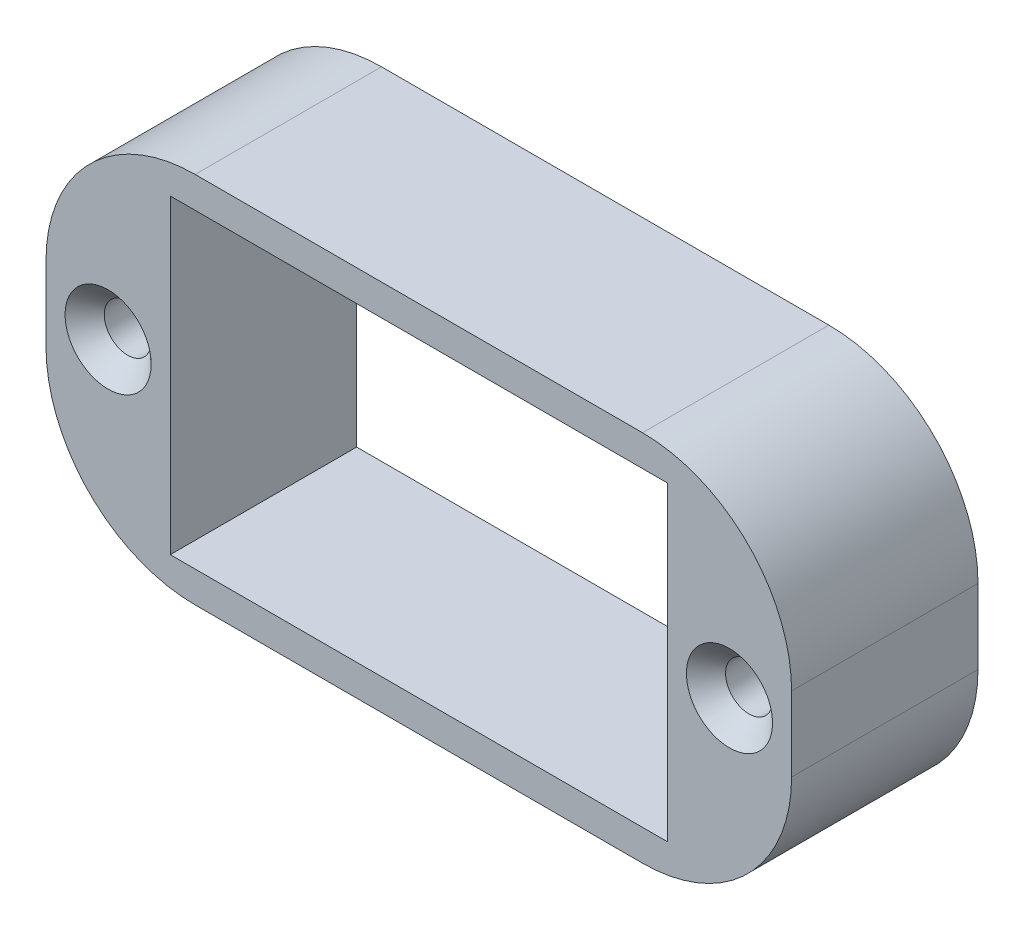
from build123d import *

# Parameters (mm, degrees)
SKETCH1_W                                       = 38.1
SKETCH1_H                                       = 19.05
BOSS_EXTRUDE1_DEPTH                             = 9.525
SKETCH2_W                                       = 25.4
SKETCH2_H                                       = 15.875
CUT_EXTRUDE1_DEPTH                              = 9.525
FILLET1_R                                       = 7.62
CSK_FOR_M2_FLAT_HEAD_MACHINE_SCREW1_D           = 2.4
CSK_FOR_M2_FLAT_HEAD_MACHINE_SCREW1_CSINK_D     = 4.4
CSK_FOR_M2_FLAT_HEAD_MACHINE_SCREW1_CSINK_ANGLE = 90


with BuildPart() as part:
    # Sketch1 → Boss-Extrude1 (new body)
    with BuildSketch(Plane.XY):
        Rectangle(SKETCH1_W, SKETCH1_H)
    extrude(amount=BOSS_EXTRUDE1_DEPTH)

    # Sketch2 → Cut-Extrude1 (cut)
    with BuildSketch(Plane.XY.offset(9.525)):
        Rectangle(SKETCH2_W, SKETCH2_H)
    extrude(amount=-CUT_EXTRUDE1_DEPTH, mode=Mode.SUBTRACT)

    # Fillet1
    fillet1_edges = [part.edges().sort_by_distance(p)[0] for p in [
        (-19.05, 9.525, 4.7625),
        (19.05, 9.525, 4.7625),
        (19.05, -9.525, 4.7625),
        (-19.05, -9.525, 4.7625),
    ]]
    fillet(fillet1_edges, radius=FILLET1_R)

    # CSK for M2 Flat Head Machine Screw1 (through all)
    with Locations(Plane.XY.offset(9.525)):
        with Locations((-15.875, 0), (15.875, 0)):
            CounterSinkHole(CSK_FOR_M2_FLAT_HEAD_MACHINE_SCREW1_D / 2, CSK_FOR_M2_FLAT_HEAD_MACHINE_SCREW1_CSINK_D / 2, counter_sink_angle=CSK_FOR_M2_FLAT_HEAD_MACHINE_SCREW1_CSINK_ANGLE)


solid = part.part
